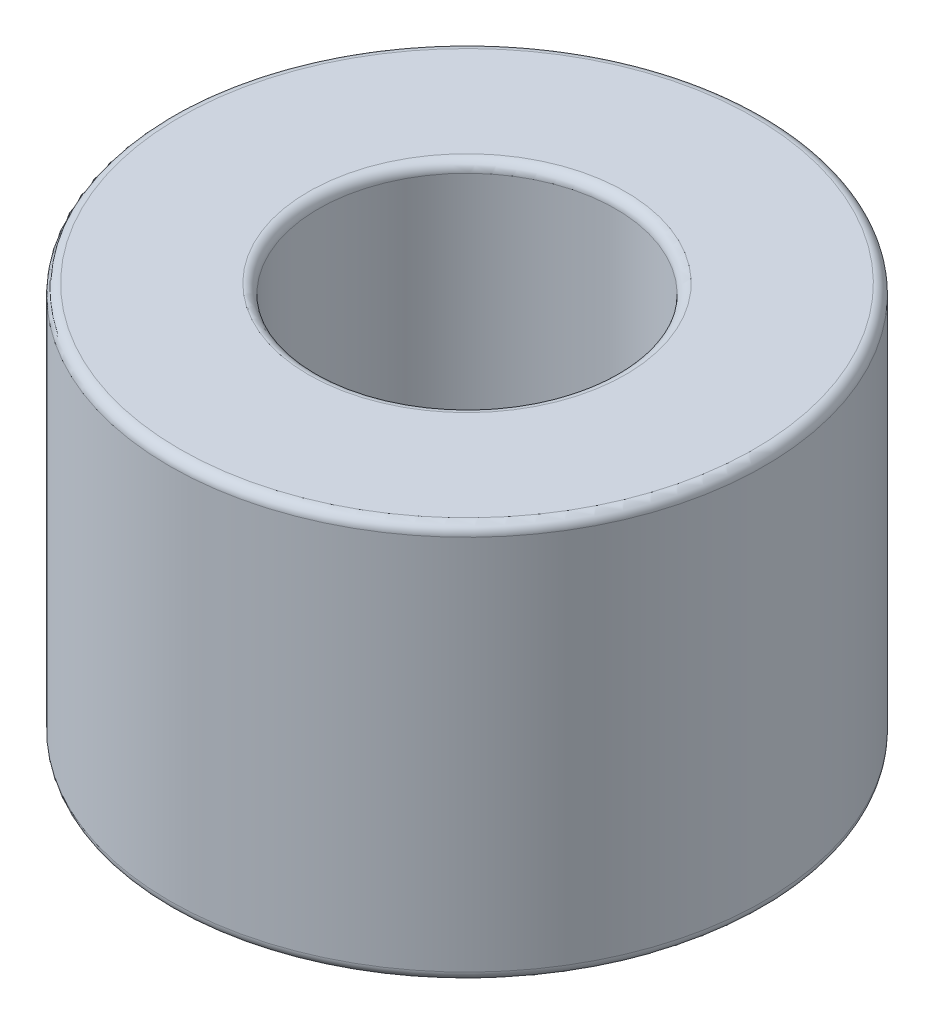
from build123d import *

# Parameters (mm, degrees)
SKETCH1_R           = 6
SKETCH1_R_2         = 3
BOSS_EXTRUDE1_DEPTH = 8
FILLET1_R           = 0.2


with BuildPart() as part:
    # Sketch1 → Boss-Extrude1 (new body)
    with BuildSketch(Plane(origin=(0, 0, 0), x_dir=(1, 0, 0), z_dir=(0, 1, 0))):
        Circle(SKETCH1_R)
        Circle(SKETCH1_R_2, mode=Mode.SUBTRACT)
    extrude(amount=BOSS_EXTRUDE1_DEPTH)

    # Fillet1
    fillet1_edges = [part.edges().sort_by_distance(p)[0] for p in [
        (-6, 0, 0),
        (-6, 8, 0),
        (-3, 0, 0),
        (-3, 8, 0),
    ]]
    fillet(fillet1_edges, radius=FILLET1_R)


solid = part.part
